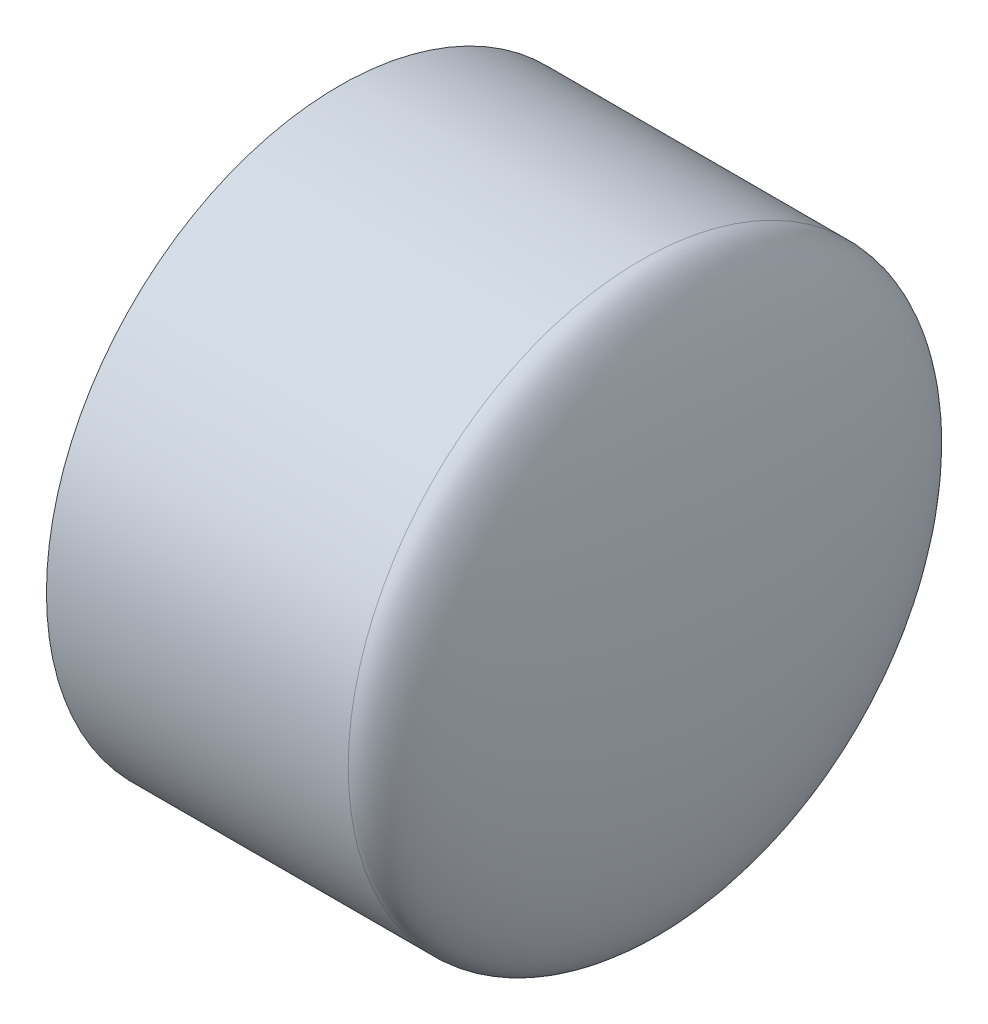
from build123d import *


with BuildPart() as part:
    # Sketch1 → Revolve1 (revolve)
    with BuildSketch(Plane.XY):
        with BuildLine():
            Line((-15.08125, 0), (0, 0))
            add(Edge.make_bspline(
                [(-15.08125, -63.896875), (0, -63.896875), (0, 0)],
                knots=[0, 0, 0, 1.570796327, 1.570796327, 1.570796327], degree=2, weights=[1, 0.707106781, 1]))
            Line((-15.08125, -63.896875), (-80.9625, -63.896875))
            Line((-80.9625, -63.896875), (-80.9625, -57.3786))
            Line((-80.9625, -57.3786), (-30.1625, -57.0357))
            add(Edge.make_bspline(
                [(-30.1625, -57.0357), (-15.08125, -57.0357), (-15.08125, 0)],
                knots=[0, 0, 0, 1.570796327, 1.570796327, 1.570796327], degree=2, weights=[1, 0.707106781, 1]))
        make_face()
    revolve(axis=Axis((-80.9625, 0, 0), (1, 0, 0)))


solid = part.part
